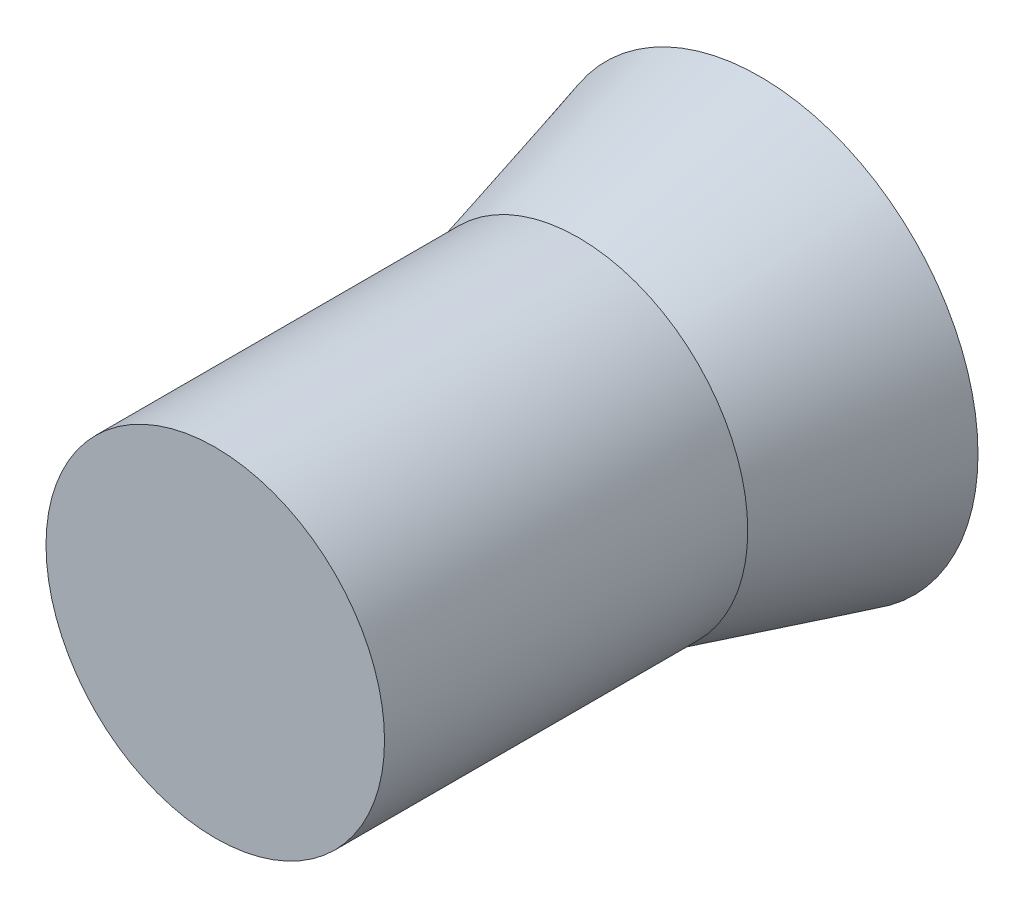
from build123d import *

# Parameters (mm, degrees)
SKETCH_1_R      = 2.4
EXTRUDE_1_DEPTH = 2
EXTRUDE_1_TAPER = 15
SKETCH_2_R      = 1.864101615
EXTRUDE_2_DEPTH = 4


with BuildPart() as part:
    # 草圖1 → 填料-伸長1 (new body)
    with BuildSketch(Plane.XY):
        Circle(SKETCH_1_R)
    extrude(amount=EXTRUDE_1_DEPTH, taper=EXTRUDE_1_TAPER)

    # 草圖2 → 填料-伸長2 (add)
    with BuildSketch(Plane.XY.offset(2)):
        Circle(SKETCH_2_R)
    extrude(amount=EXTRUDE_2_DEPTH)


solid = part.part
